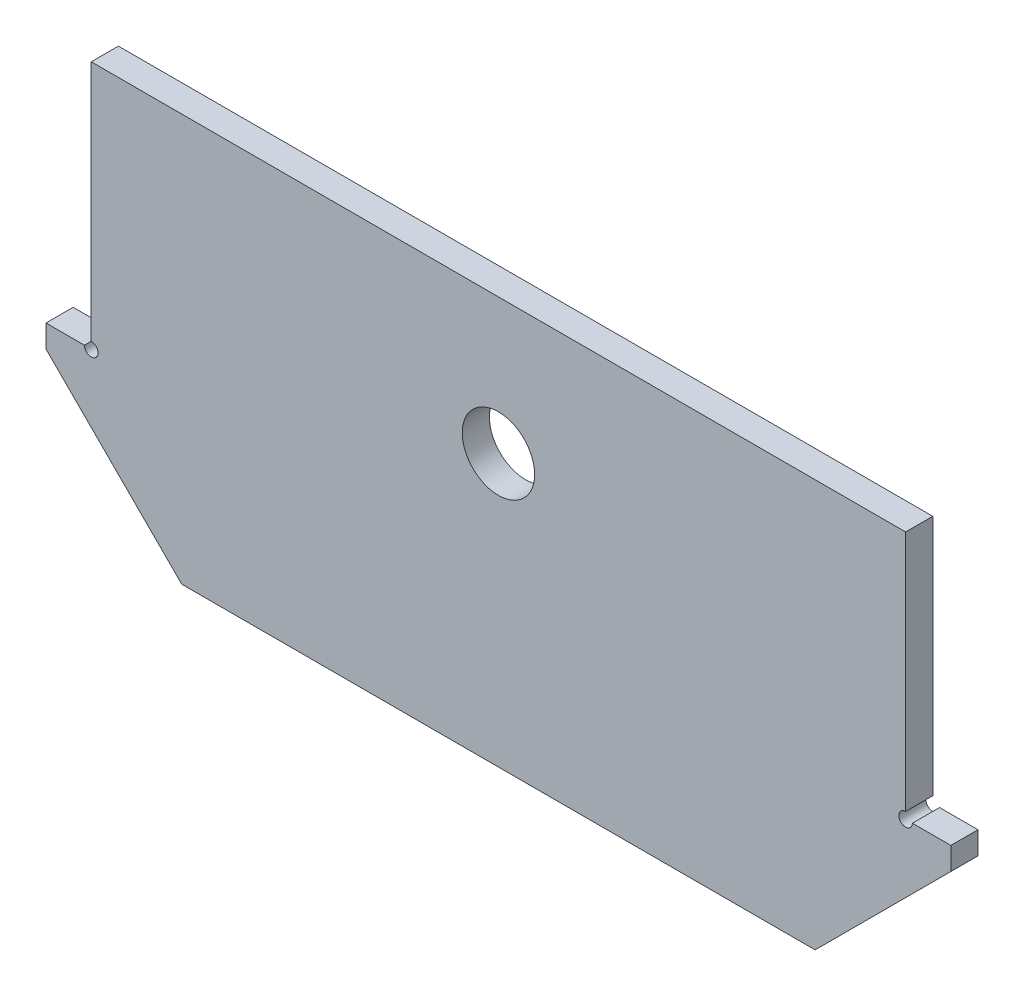
from build123d import *

# Parameters (mm, degrees)
BOSS_EXTRUDE1_DEPTH      = 3
BOSS_EXTRUDE1_DEPTH_BACK = 3
CUT_EXTRUDE1_DEPTH       = 1453.458955414
CUT_EXTRUDE1_DEPTH_BACK  = 1453.458955414
SKETCH2_R                = 8
CUT_EXTRUDE2_DEPTH       = 1453.458955414
CUT_EXTRUDE2_DEPTH_BACK  = 1453.458955414
SKETCH3_R                = 1.5


with BuildPart() as part:
    # Sketch1 → Boss-Extrude1 (new, two sides: drawn at the far end of the back side and taken through both)
    with BuildSketch(Plane.XY.offset(-BOSS_EXTRUDE1_DEPTH_BACK)):
        Polygon((-90, -1414.000005922), (-90, -1359.000005922), (90, -1359.000005922), (90, -1414.000005922), (100, -1414.000005922), (100, -1419.000005922), (70, -1449.000005922), (-70, -1449.000005922), (-100, -1419.000005922), (-100, -1414.000005922), align=None)
    extrude(amount=BOSS_EXTRUDE1_DEPTH + BOSS_EXTRUDE1_DEPTH_BACK)

    # Sketch2 → Cut-Extrude1 (cut, two sides: drawn at the far end of the back side and taken through both)
    with BuildSketch(Plane.XY.offset(3).offset(-CUT_EXTRUDE1_DEPTH_BACK)):
        with Locations((0, -1389.000005922)):
            Circle(SKETCH2_R)
    extrude(amount=CUT_EXTRUDE1_DEPTH + CUT_EXTRUDE1_DEPTH_BACK, mode=Mode.SUBTRACT)

    # Sketch3 → Cut-Extrude2 (cut, two sides: drawn at the far end of the back side and taken through both)
    with BuildSketch(Plane.XY.offset(3).offset(-CUT_EXTRUDE2_DEPTH_BACK)):
        with Locations((-90, -1414.000005922)):
            Circle(SKETCH3_R)
        with Locations((90, -1414.000005922)):
            Circle(SKETCH3_R)
    extrude(amount=CUT_EXTRUDE2_DEPTH + CUT_EXTRUDE2_DEPTH_BACK, mode=Mode.SUBTRACT)


solid = part.part
